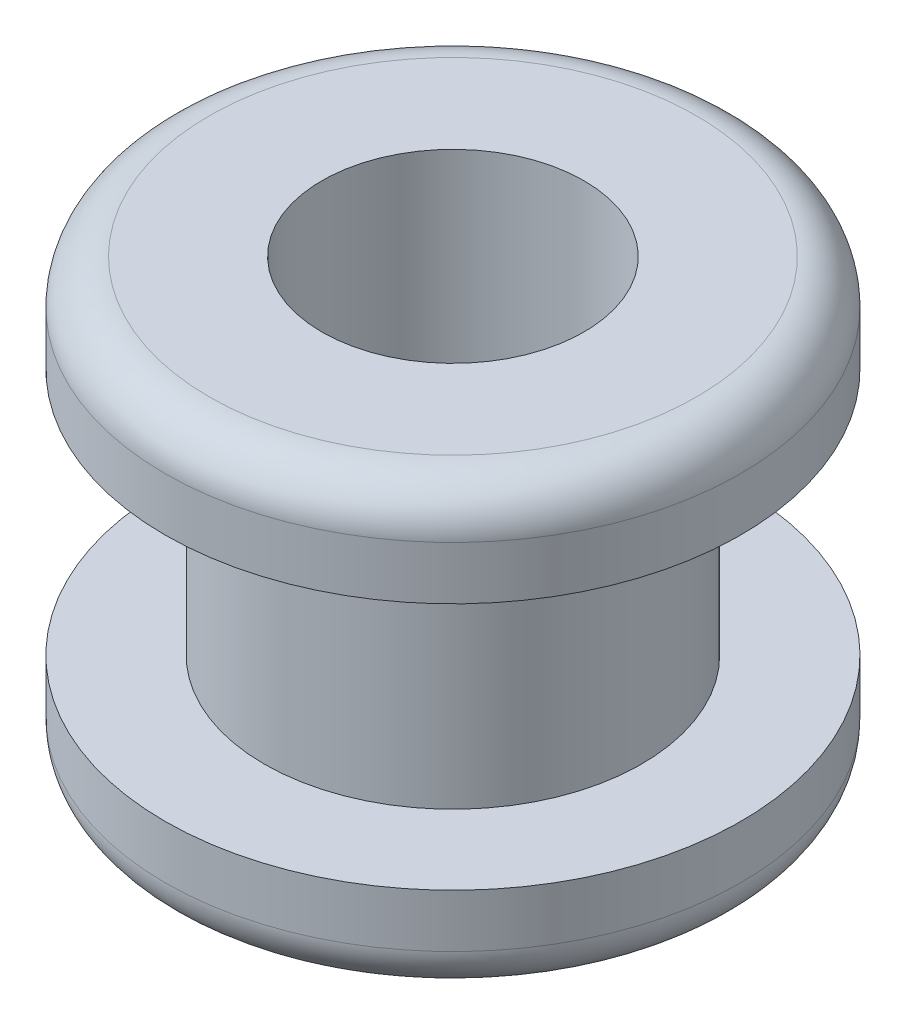
from build123d import *


with BuildPart() as part:
    # Çizim1 → Döndür1 (revolve)
    with BuildSketch(Plane(origin=(0, 0, 0), x_dir=(0, 0, -1), z_dir=(1, 0, 0))):
        with BuildLine():
            Line((0, 5), (0, 0))
            Line((0, 0), (-1.27, 0))
            ThreePointArc((-1.27, 0), (-1.623553391, 0.146446609), (-1.77, 0.5))
            Line((-1.77, 0.5), (-1.77, 1.1))
            Line((-1.77, 1.1), (-0.65, 1.1))
            Line((-0.65, 1.1), (-0.65, 3.9))
            Line((-0.65, 3.9), (-1.77, 3.9))
            Line((-1.77, 3.9), (-1.77, 4.5))
            ThreePointArc((-1.77, 4.5), (-1.623553391, 4.853553391), (-1.27, 5))
            Line((-1.27, 5), (0, 5))
        make_face()
    revolve(axis=Axis((0, 5, -1.48), (0, -1, 0)))


solid = part.part
